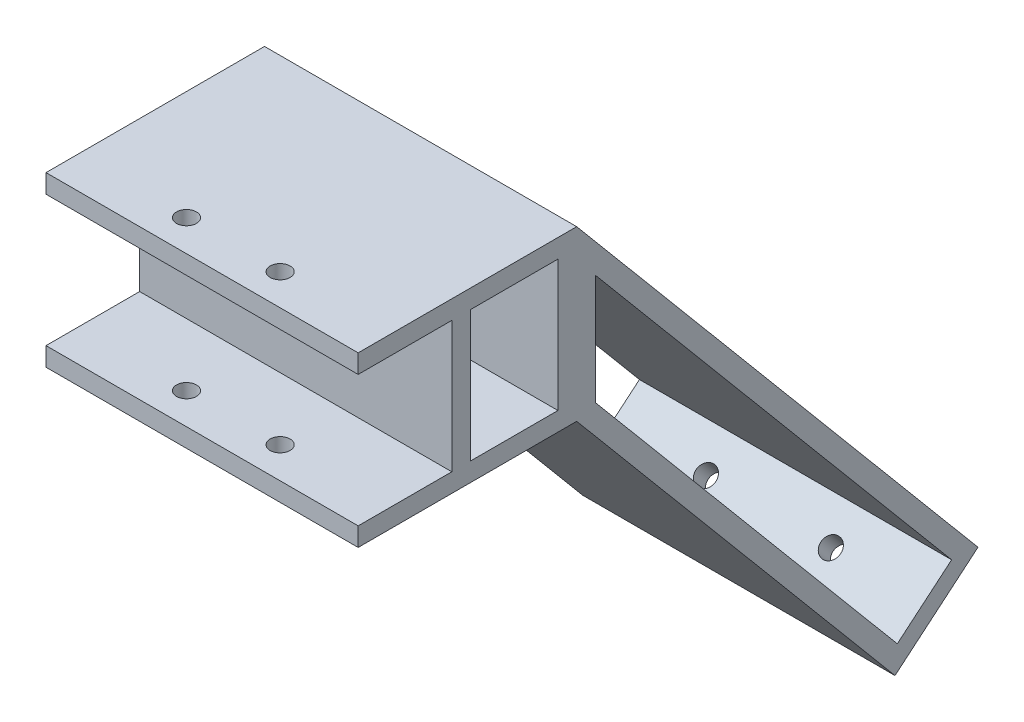
from build123d import *

# Parameters (mm, degrees)
SKETCH_1_W          = 50
SKETCH_1_H          = 27
EXTRUDE_1_DEPTH     = 35
SKETCH_2_W          = 50
SKETCH_2_H          = 21
CUT_EXTRUDE_1_DEPTH = 15
SKETCH_3_R          = 1.6
CUT_EXTRUDE_2_DEPTH = 28
SKETCH_4_W          = 14
SKETCH_4_H          = 21
CUT_EXTRUDE_3_DEPTH = 51
EXTRUDE_2_DEPTH     = 50
CUT_EXTRUDE_4_DEPTH = 51
SKETCH_8_R          = 1.6
CUT_EXTRUDE_5_DEPTH = 50


with BuildPart() as part:
    # 草图1 → 凸台-拉伸1 (new body)
    with BuildSketch(Plane.XY):
        with Locations((3.800856531, -0.170235546)):
            Rectangle(SKETCH_1_W, SKETCH_1_H)
    extrude(amount=EXTRUDE_1_DEPTH)

    # 草图2 → 切除-拉伸1 (cut)
    with BuildSketch(Plane.XY.offset(35)):
        with Locations((3.800856531, -0.170235546)):
            Rectangle(SKETCH_2_W, SKETCH_2_H)
    extrude(amount=-CUT_EXTRUDE_1_DEPTH, mode=Mode.SUBTRACT)

    # 草图3 → 切除-拉伸2 (cut, through all)
    with BuildSketch(Plane.XZ.offset(13.670235546)):
        with Locations((-3.699143469, 30)):
            Circle(SKETCH_3_R)
        with Locations((11.300856531, 30)):
            Circle(SKETCH_3_R)
    extrude(amount=-CUT_EXTRUDE_2_DEPTH, mode=Mode.SUBTRACT)

    # 草图4 → 切除-拉伸3 (cut, through all)
    with BuildSketch(Plane.ZY.offset(21.199143469)):
        with Locations((10, -0.170235546)):
            Rectangle(SKETCH_4_W, SKETCH_4_H)
    extrude(amount=-CUT_EXTRUDE_3_DEPTH, mode=Mode.SUBTRACT)

    # 草图6 → 凸台-拉伸2 (add)
    with BuildSketch(Plane(origin=(28.800856531, 0, 0), x_dir=(0, 0, -1), z_dir=(1, 0, 0))):
        Polygon((0, -13.670235546), (50.983856303, -74.430429459), (64.278760969, -63.274679858), (0, 13.329764454), align=None)
    extrude(amount=-EXTRUDE_2_DEPTH)

    # 草图7 → 切除-拉伸4 (cut, through all)
    with BuildSketch(Plane(origin=(28.800856531, 0, 0), x_dir=(0, 0, -1), z_dir=(1, 0, 0))):
        Polygon((60.05226481, -62.904909358), (3, 5.087332196), (3, -12.578324843), (51.353626803, -70.203933301), align=None)
    extrude(amount=-CUT_EXTRUDE_4_DEPTH, mode=Mode.SUBTRACT)

    # 草图8 → 切除-拉伸5 (cut)
    with BuildSketch(Plane(origin=(0, -68.782217432, -57.715133279), x_dir=(-1, 0, 0), z_dir=(0, -0.766044443, -0.64278761))):
        with Locations((-13.800856531, -0.1094253)):
            Circle(SKETCH_8_R)
        with Locations((6.199143469, -0.1094253)):
            Circle(SKETCH_8_R)
    extrude(amount=-CUT_EXTRUDE_5_DEPTH, mode=Mode.SUBTRACT)


solid = part.part
